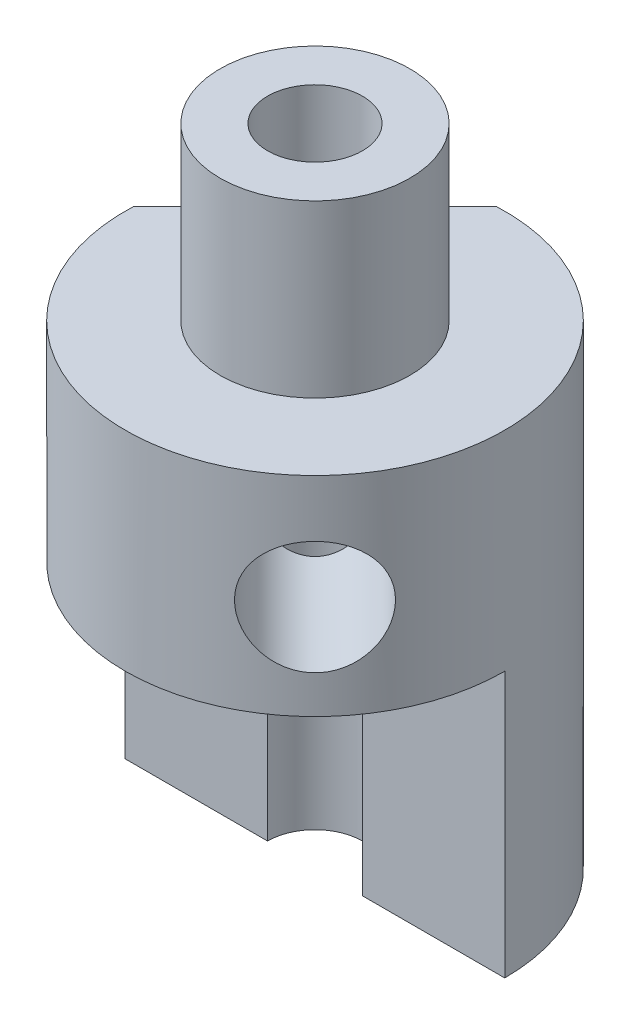
from build123d import *

# Parameters (mm, degrees)
CUT_EXTRUDE_1_DEPTH             = 7
CUT_EXTRUDE_2_DEPTH             = 18
SKETCH_5_R                      = 1.5
CUT_EXTRUDE_3_DEPTH             = 4.388378183
CUT_EXTRUDE_3_DIRECTION_2_REACH = 12.754


with BuildPart() as part:
    # Эскиз1 → Повернуть1 (revolve)
    with BuildSketch(Plane(origin=(0, 0, 0), x_dir=(0, 0, -1), z_dir=(1, 0, 0))):
        Polygon((2.5, -4.5), (2.5, 0), (1.25, 0), (1.25, -17), (5, -17), (5, -4.5), align=None)
    revolve(axis=Axis((0, 0, 0), (0, -1, 0)))

    # Эскиз2 → Вырез-Вытянуть1 (cut)
    with BuildSketch(Plane.XZ.offset(17)):
        Polygon((-37.360679775, 0), (-5, 0), (5, 0), (37.360679775, 0), (37.360679775, 64.72135955), (-37.360679775, 64.72135955), align=None)
    extrude(amount=-CUT_EXTRUDE_1_DEPTH, mode=Mode.SUBTRACT)

    # Эскиз3 → Вырез-Вытянуть2 (cut, through all)
    with BuildSketch(Plane.XZ.offset(17)):
        with BuildLine():
            Line((-0.212632943, -4.995476677), (-4.995476677, -0.212632943))
            ThreePointArc((-4.995476677, -0.212632943), (-3.535533906, -3.535533906), (-0.212632943, -4.995476677))
        make_face()
    extrude(amount=-CUT_EXTRUDE_2_DEPTH, mode=Mode.SUBTRACT)

    # Эскиз5 → Вырез-Вытянуть3 (cut)
    with BuildSketch(Plane(origin=(-7.70810962, 0, 2.5), x_dir=(0.707106781, 0, -0.707106781), z_dir=(0.707106781, 0, 0.707106781))):
        with Locations((7.218223535, -7.5)):
            Circle(SKETCH_5_R)
    extrude(amount=-CUT_EXTRUDE_3_DEPTH, mode=Mode.SUBTRACT)

    # Эскиз5 → Вырез-Вытянуть3 direction 2 (cut, up to next)
    with BuildSketch(Plane(origin=(-7.70810962, 0, 2.5), x_dir=(0.707106781, 0, -0.707106781), z_dir=(0.707106781, 0, 0.707106781)), mode=Mode.PRIVATE) as cut_extrude_3_direction_2_sk1:
        with Locations((7.218223535, -7.5)):
            Circle(SKETCH_5_R)
    cut_extrude_3_direction_2_tool1 = extrude(cut_extrude_3_direction_2_sk1.sketch, amount=CUT_EXTRUDE_3_DIRECTION_2_REACH, mode=Mode.PRIVATE) & part.part
    add(cut_extrude_3_direction_2_tool1.solids().sort_by_distance((-2.604055, -7.5, -2.604055))[0], mode=Mode.SUBTRACT)


solid = part.part
